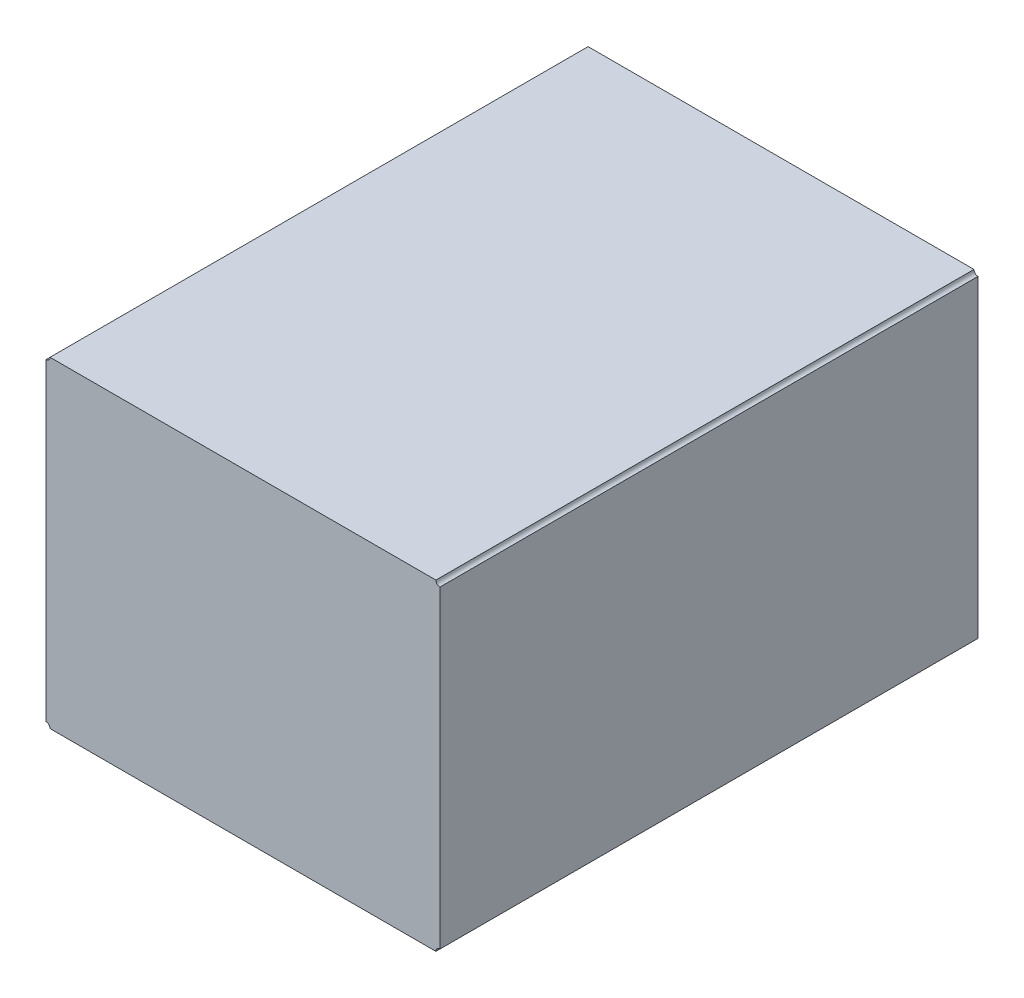
from build123d import *

# Parameters (mm, degrees)
EXTRUDE_1_DEPTH = 8.5


with BuildPart() as part:
    # 草图1 → 凸台-拉伸1 (new body)
    with BuildSketch(Plane.XY):
        with BuildLine():
            ThreePointArc((97.3455, 85.344), (97.364098719, 85.388901281), (97.409, 85.4075))
            Line((97.409, 85.4075), (97.409, 90.3605))
            ThreePointArc((97.409, 90.3605), (97.364098719, 90.379098719), (97.3455, 90.424))
            Line((97.3455, 90.424), (91.2495, 90.424))
            ThreePointArc((91.2495, 90.424), (91.230901281, 90.379098719), (91.186, 90.3605))
            Line((91.186, 90.3605), (91.186, 85.4075))
            ThreePointArc((91.186, 85.4075), (91.230901281, 85.388901281), (91.2495, 85.344))
            Line((91.2495, 85.344), (97.3455, 85.344))
        make_face()
    extrude(amount=EXTRUDE_1_DEPTH)


solid = part.part
